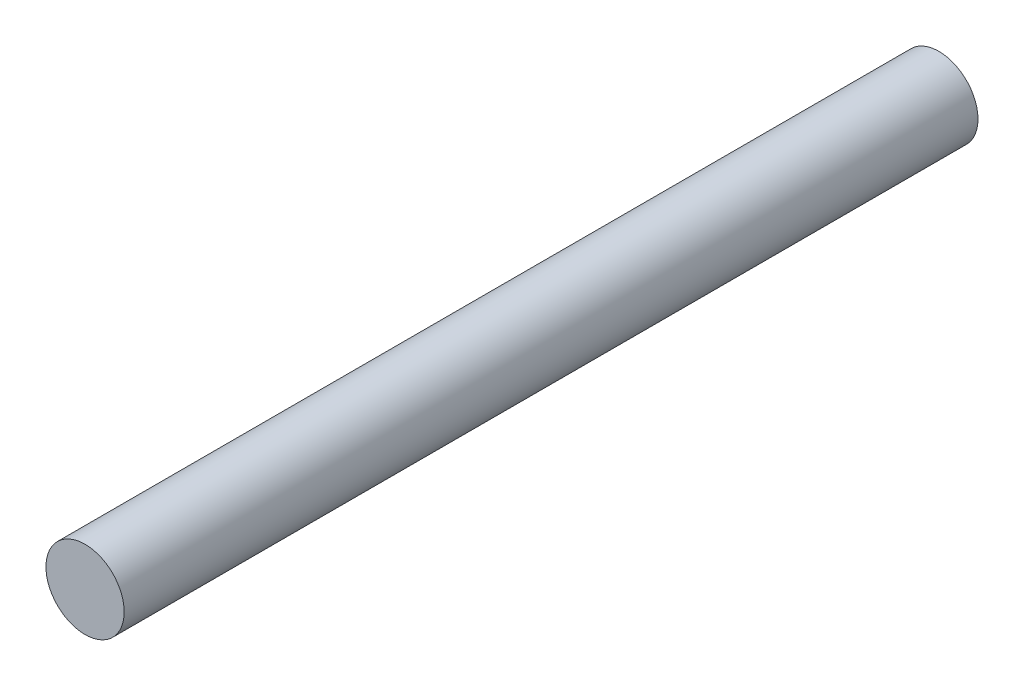
from build123d import *

# Parameters (mm, degrees)
SKICA1_R                = 1.65
P_IDAT_VYSUNUT_M1_DEPTH = 36


with BuildPart() as part:
    # Skica1 → Přidat vysunutím1 (new body)
    with BuildSketch(Plane.XY):
        Circle(SKICA1_R)
    extrude(amount=P_IDAT_VYSUNUT_M1_DEPTH)


solid = part.part
